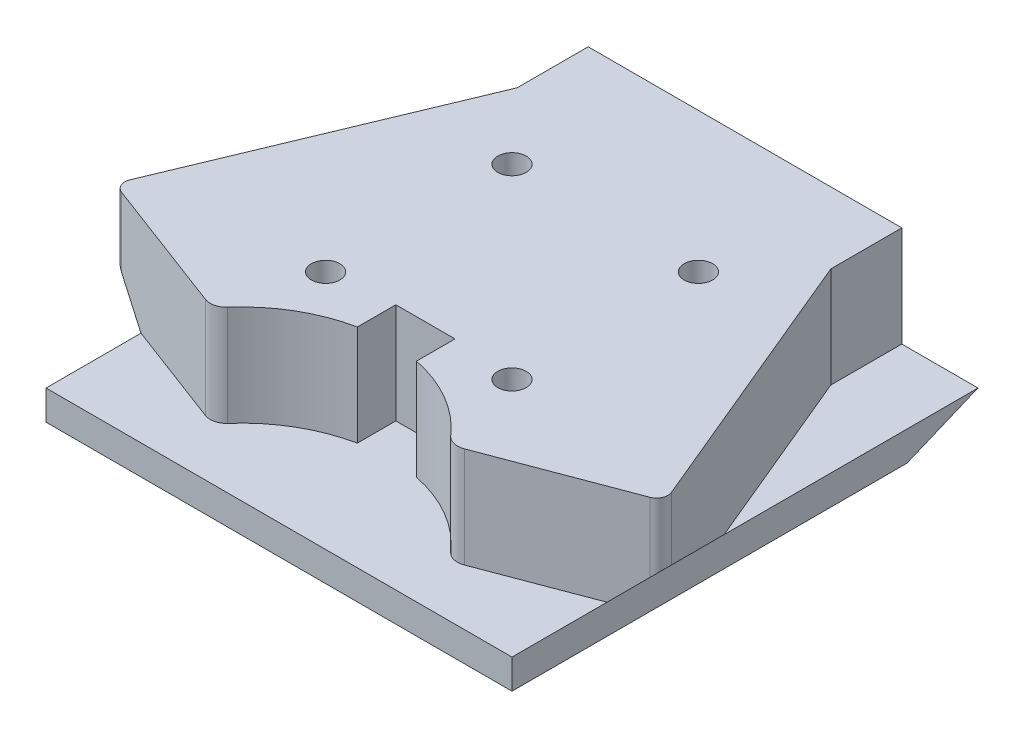
from build123d import *

# Parameters (mm, degrees)
BOSS_EXTRUDE1_DEPTH = 10.795
BOSS_EXTRUDE2_DEPTH = 3.175
CUT_EXTRUDE1_DEPTH  = 55.133861737
CUT_EXTRUDE3_DEPTH  = 50.9999
SKETCH5_R           = 1.524
CUT_EXTRUDE4_DEPTH  = 14.97


with BuildPart() as part:
    # Sketch1 → Boss-Extrude1 (new body)
    with BuildSketch(Plane(origin=(0, 0, 0), x_dir=(1, 0, 0), z_dir=(0, 1, 0))):
        with BuildLine():
            Line((0, 0), (33.655, 0))
            Line((33.655, 0), (33.655, -7.62))
            Line((33.655, -7.62), (45.882312708, -36.965550498))
            ThreePointArc((45.882312708, -36.965550498), (45.852364547, -37.905157075), (45.166785817, -38.548382711))
            Line((45.166785817, -38.548382711), (30.715714183, -44.001617289))
            ThreePointArc((30.715714183, -44.001617289), (29.6938714, -44.069401845), (28.806656699, -43.557926045))
            ThreePointArc((28.806656699, -43.557926045), (24.828111607, -40.263477877), (20.0025, -38.420740133))
            Line((20.0025, -38.420740133), (20.0025, -38.1))
            Line((20.0025, -38.1), (20.0025, -34.29))
            Line((20.0025, -34.29), (13.6525, -34.29))
            Line((13.6525, -34.29), (13.6525, -38.1))
            Line((13.6525, -38.1), (13.6525, -38.420740133))
            ThreePointArc((13.6525, -38.420740133), (8.826888393, -40.263477877), (4.848343301, -43.557926045))
            ThreePointArc((4.848343301, -43.557926045), (3.9611286, -44.069401845), (2.939285817, -44.001617289))
            Line((2.939285817, -44.001617289), (-11.511785817, -38.548382711))
            ThreePointArc((-11.511785817, -38.548382711), (-12.197364547, -37.905157075), (-12.227312708, -36.965550498))
            Line((-12.227312708, -36.965550498), (0, -7.62))
            Line((0, -7.62), (0, 0))
        make_face()
    extrude(amount=BOSS_EXTRUDE1_DEPTH)

    # Sketch2 → Boss-Extrude2 (add)
    with BuildSketch(Plane.XZ):
        Polygon((16.8275, 0), (-8.17245, 0), (-8.17245, 49.9999), (41.82745, 49.9999), (41.82745, 0), align=None)
    extrude(amount=BOSS_EXTRUDE2_DEPTH)

    # Sketch3 → Cut-Extrude1 (cut, through all)
    with BuildSketch(Plane.ZY.offset(8.17245)):
        Polygon((7.62, -3.175), (0, 0), (0, -3.175), align=None)
    extrude(amount=-CUT_EXTRUDE1_DEPTH, mode=Mode.SUBTRACT)

    # Sketch4 → Cut-Extrude3 (cut, through all)
    with BuildSketch(Plane(origin=(0, 0, 0), x_dir=(-1, 0, 0), z_dir=(0, 0, -1))):
        Polygon((-41.82745, 0), (-47.971594171, 0), (-47.971594171, 6.144144171), align=None)
        Polygon((8.17245, 0), (16.073165013, 0), (16.073165013, 7.900715013), align=None)
    extrude(amount=-CUT_EXTRUDE3_DEPTH, mode=Mode.SUBTRACT)

    # Sketch5 → Cut-Extrude4 (cut, through all)
    with BuildSketch(Plane.XZ.offset(3.175)):
        with Locations((6.8274946, 34.9999554)):
            Circle(SKETCH5_R)
        with Locations((26.8275054, 34.9999554)):
            Circle(SKETCH5_R)
        with Locations((6.8274946, 14.9999446)):
            Circle(SKETCH5_R)
        with Locations((26.8275054, 14.9999446)):
            Circle(SKETCH5_R)
    extrude(amount=-CUT_EXTRUDE4_DEPTH, mode=Mode.SUBTRACT)


solid = part.part
